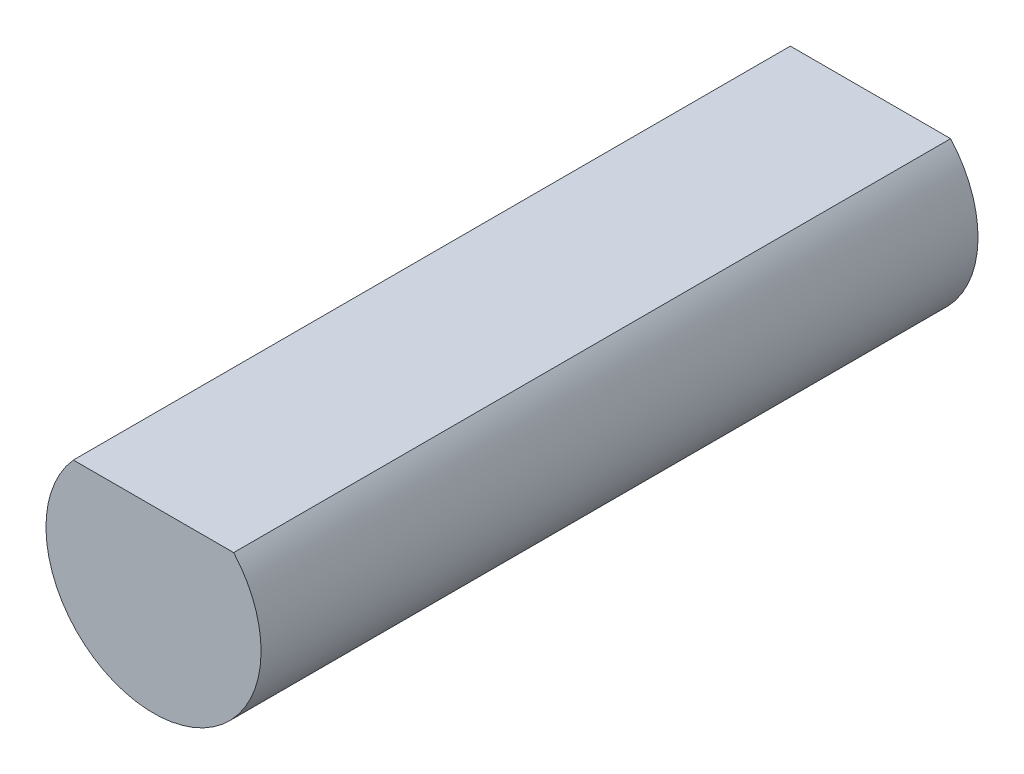
from build123d import *

# Parameters (mm, degrees)
SKETCH_1_R          = 1.5
EXTRUDE_1_DEPTH     = 10
CUT_EXTRUDE_1_DEPTH = 10


with BuildPart() as part:
    # 草图1 → 凸台-拉伸1 (new body)
    with BuildSketch(Plane.XY):
        Circle(SKETCH_1_R)
    extrude(amount=EXTRUDE_1_DEPTH)

    # 草图2 → 切除-拉伸1 (cut)
    with BuildSketch(Plane.XY.offset(10)):
        with BuildLine():
            ThreePointArc((1.118033989, 1), (0, 1.5), (-1.118033989, 1))
            Line((-1.118033989, 1), (0, 1))
            Line((0, 1), (1.118033989, 1))
        make_face()
    extrude(amount=-CUT_EXTRUDE_1_DEPTH, mode=Mode.SUBTRACT)


solid = part.part
